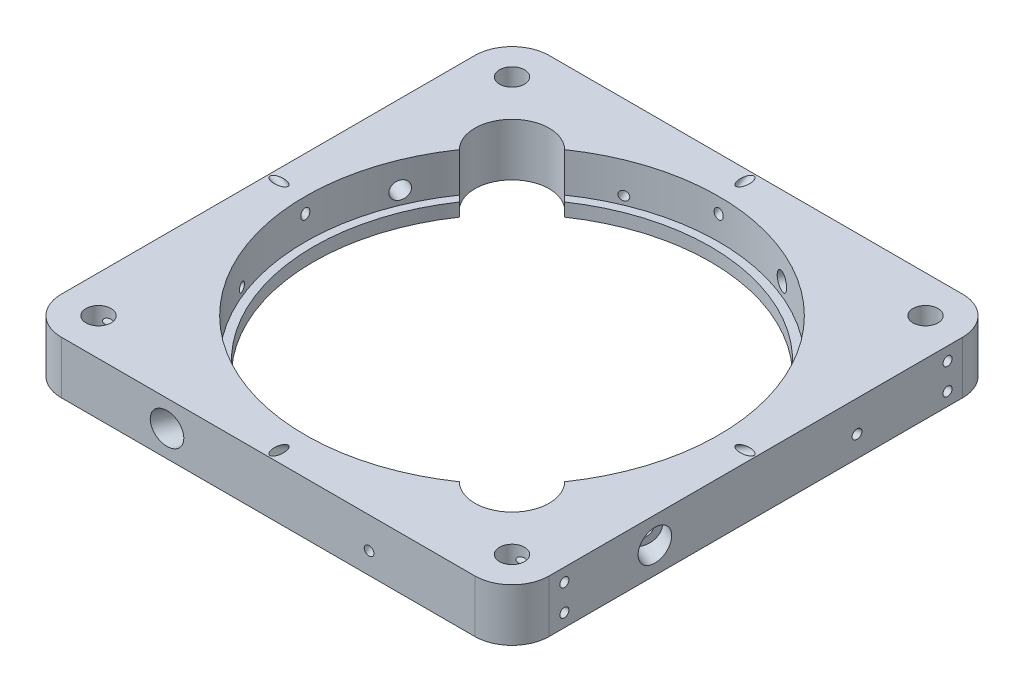
from build123d import *

# Parameters (mm, degrees)
SKETCH1_R                           = 3.025
BOSS_EXTRUDE1_DEPTH                 = 12.7
SKETCH2_R                           = 1.095
CUT_EXTRUDE1_DEPTH                  = 15
SKETCH5_R                           = 2.1
CUT_EXTRUDE2_DEPTH                  = 85.399585392
SKETCH6_R                           = 1.095
CUT_EXTRUDE3_DEPTH                  = 85.399585462
CUT_EXTRUDE4_REACH                  = 123.632
SKETCH7_R                           = 1.095
CUT_EXTRUDE4_DIRECTION_2_REACH      = 123.632
CUT_EXTRUDE4_DIRECTION_2_END_RADIUS = 50
CIRPATTERN1_COUNT                   = 4
CUT_EXTRUDE5_DEPTH                  = 85.399585462
CIRPATTERN2_COUNT                   = 2
CUT_EXTRUDE6_START                  = -148.732915462
SKETCH9_R                           = 3.75
CUT_EXTRUDE6_DEPTH                  = 90.399585462
CIRPATTERN6_COUNT                   = 4


with BuildPart() as part:
    # Sketch1 → Boss-Extrude1 (new body)
    with BuildSketch(Plane(origin=(0, 0, 0), x_dir=(1, 0, 0), z_dir=(0, 1, 0))):
        with BuildLine():
            Line((-50, 59), (50, 59))
            ThreePointArc((50, 59), (56.363961031, 56.363961031), (59, 50))
            Line((59, 50), (59, -50))
            ThreePointArc((59, -50), (56.363961031, -56.363961031), (50, -59))
            Line((50, -59), (-50, -59))
            ThreePointArc((-50, -59), (-56.363961031, -56.363961031), (-59, -50))
            Line((-59, -50), (-59, 50))
            ThreePointArc((-59, 50), (-56.363961031, 56.363961031), (-50, 59))
        make_face()
        with Locations(Location((50, 50, 0), (0, 0, 270))):
            Circle(SKETCH1_R, mode=Mode.SUBTRACT)
        with Locations(Location((50, -50, 0), (0, 0, 270))):
            Circle(SKETCH1_R, mode=Mode.SUBTRACT)
        with Locations(Location((-50, 50, 0), (0, 0, 270))):
            Circle(SKETCH1_R, mode=Mode.SUBTRACT)
        with Locations(Location((-50, -50, 0), (0, 0, 270))):
            Circle(SKETCH1_R, mode=Mode.SUBTRACT)
    extrude(amount=BOSS_EXTRUDE1_DEPTH)

    # Sketch2 → Cut-Extrude1 (cut)
    with BuildSketch(Plane(origin=(59, 0, 0), x_dir=(0, 0, -1), z_dir=(1, 0, 0))):
        with Locations((-46.34, 9.525)):
            Circle(SKETCH2_R)
        with Locations((-46.34, 3.175)):
            Circle(SKETCH2_R)
        with Locations((46.34, 9.525)):
            Circle(SKETCH2_R)
        with Locations((46.34, 3.175)):
            Circle(SKETCH2_R)
    cut_extrude1 = extrude(amount=-CUT_EXTRUDE1_DEPTH, mode=Mode.SUBTRACT)

    # Mirror1: Cut-Extrude1 across plane
    add(cut_extrude1.mirror(Plane(origin=(0, 0, 0), x_dir=(0, 0, 1), z_dir=(1, 0, 0))), mode=Mode.SUBTRACT)

    # Sketch4 → Cut-Revolve1 (revolve, cut)
    with BuildSketch(Plane.XY):
        Polygon((0, 0), (0, 12.7), (50, 12.7), (50, 3.175), (48, 3.175), (48, 0), align=None)
    revolve(axis=Axis((0, 0, 0), (0, 1, 0)), mode=Mode.SUBTRACT)

    # Sketch5 → Cut-Extrude2 (cut, through all)
    with BuildSketch(Plane(origin=(0, 0, 0), x_dir=(0.9238795325112865, 0, 0.3826834323650906), z_dir=(-0.38268343236509056, 0, 0.9238795325112864))):
        with Locations((0, 6.35)):
            Circle(SKETCH5_R)
    cut_extrude2 = extrude(amount=-CUT_EXTRUDE2_DEPTH, mode=Mode.SUBTRACT)

    # Sketch6 → Cut-Extrude3 (cut, through all)
    with BuildSketch(Plane(origin=(0, 0, 0), x_dir=(0.3826834323650874, 0, 0.9238795325112878), z_dir=(-0.9238795325112878, 0, 0.3826834323650874))):
        with Locations((0, 5.175)):
            Circle(SKETCH6_R)
    cut_extrude3 = extrude(amount=-CUT_EXTRUDE3_DEPTH, mode=Mode.SUBTRACT)

    # Cut-Extrude4: up to this plane
    cut_extrude4_end = Plane(origin=(-50, 12.7, 50), z_dir=(0, 1, 0))
    # Sketch7 → Cut-Extrude4 (cut, up to the surface)
    with BuildSketch(Plane(origin=(0, 25.547749412, 44.25), x_dir=(-1, 0, 0), z_dir=(0, -0.500000000000001, -0.866025403784438)), mode=Mode.PRIVATE) as cut_extrude4_sk1:
        with Locations(Location((0, -17.176477372, 0), (0, 0, 90))):
            Circle(SKETCH7_R)
    cut_extrude4_tool1 = split(extrude(cut_extrude4_sk1.sketch, amount=-CUT_EXTRUDE4_REACH, mode=Mode.PRIVATE), bisect_by=cut_extrude4_end, keep=Keep.BOTH, mode=Mode.PRIVATE)
    cut_extrude4 = cut_extrude4_tool1.solids().sort_by_distance((0, 10.672484, 52.838239))[0]
    add(cut_extrude4, mode=Mode.SUBTRACT)

    # Cut-Extrude4 direction 2: up to this cylinder (the profile starts outside it)
    cut_extrude4_direction_2_end = Plane(origin=(0, 10.672484, 0), z_dir=(0, -1, 0)) * Cylinder(CUT_EXTRUDE4_DIRECTION_2_END_RADIUS, 348.264, mode=Mode.PRIVATE)
    # Sketch7 → Cut-Extrude4 direction 2 (cut, up to the surface)
    with BuildSketch(Plane(origin=(0, 25.547749412, 44.25), x_dir=(-1, 0, 0), z_dir=(0, -0.500000000000001, -0.866025403784438)), mode=Mode.PRIVATE) as cut_extrude4_direction_2_sk1:
        with Locations(Location((0, -17.176477372, 0), (0, 0, 90))):
            Circle(SKETCH7_R)
    cut_extrude4_direction_2_tool1 = extrude(cut_extrude4_direction_2_sk1.sketch, amount=CUT_EXTRUDE4_DIRECTION_2_REACH, mode=Mode.PRIVATE) - cut_extrude4_direction_2_end
    cut_extrude4_direction_2 = cut_extrude4_direction_2_tool1.solids().sort_by_distance((0, 10.672484, 52.838239))[0]
    add(cut_extrude4_direction_2, mode=Mode.SUBTRACT)
    cut_extrude4 = cut_extrude4 + cut_extrude4_direction_2  # both directions under the feature's name, for the pattern or mirror that repeats it

    # CirPattern1: Cut-Extrude2, Cut-Extrude3, Cut-Extrude4 ×4 about axis
    cirpattern1_axis = Axis((0, 13.335, 0), (0, -1, 0))
    add([cut_extrude2.rotate(cirpattern1_axis, i * 360 / CIRPATTERN1_COUNT) for i in range(1, CIRPATTERN1_COUNT)], mode=Mode.SUBTRACT)
    add([cut_extrude3.rotate(cirpattern1_axis, i * 360 / CIRPATTERN1_COUNT) for i in range(1, CIRPATTERN1_COUNT)], mode=Mode.SUBTRACT)
    add([cut_extrude4.rotate(cirpattern1_axis, i * 360 / CIRPATTERN1_COUNT) for i in range(1, CIRPATTERN1_COUNT)], mode=Mode.SUBTRACT)

    # Sketch8 → Cut-Extrude5 (cut, through all)
    with BuildSketch(Plane(origin=(0, 12.7, 0), x_dir=(1, 0, 0), z_dir=(0, 1, 0))):
        with BuildLine():
            Line((-41.141827555, 28.413905494), (-39.703127187, 26.975205126))
            Line((-39.703127187, 26.975205126), (-26.975205126, 39.703127187))
            Line((-26.975205126, 39.703127187), (-28.413905494, 41.141827555))
            ThreePointArc((-28.413905494, 41.141827555), (-41.141827555, 41.141827555), (-41.141827555, 28.413905494))
        make_face()
    cut_extrude5 = extrude(amount=-CUT_EXTRUDE5_DEPTH, mode=Mode.SUBTRACT)

    # CirPattern2: Cut-Extrude5 ×2 about axis
    cirpattern2_axis = Axis((0, 0, 0), (0, 1, 0))
    for i in range(1, CIRPATTERN2_COUNT):
        add(cut_extrude5.rotate(cirpattern2_axis, i * 360 / CIRPATTERN2_COUNT), mode=Mode.SUBTRACT)

    # Sketch9 → Cut-Extrude6 (cut)
    with BuildSketch(Plane(origin=(0, 0, 0), x_dir=(0.9238795325112865, 0, 0.3826834323650906), z_dir=(-0.38268343236509056, 0, 0.9238795325112864)).offset(CUT_EXTRUDE6_START)):
        with Locations((0, 6.35)):
            Circle(SKETCH9_R)
    cut_extrude6 = extrude(amount=CUT_EXTRUDE6_DEPTH, mode=Mode.SUBTRACT)

    # CirPattern6: Cut-Extrude6 ×4 about axis
    cirpattern6_axis = Axis((0, 0, 0), (0, 1, 0))
    for i in range(1, CIRPATTERN6_COUNT):
        add(cut_extrude6.rotate(cirpattern6_axis, i * 360 / CIRPATTERN6_COUNT), mode=Mode.SUBTRACT)


solid = part.part
